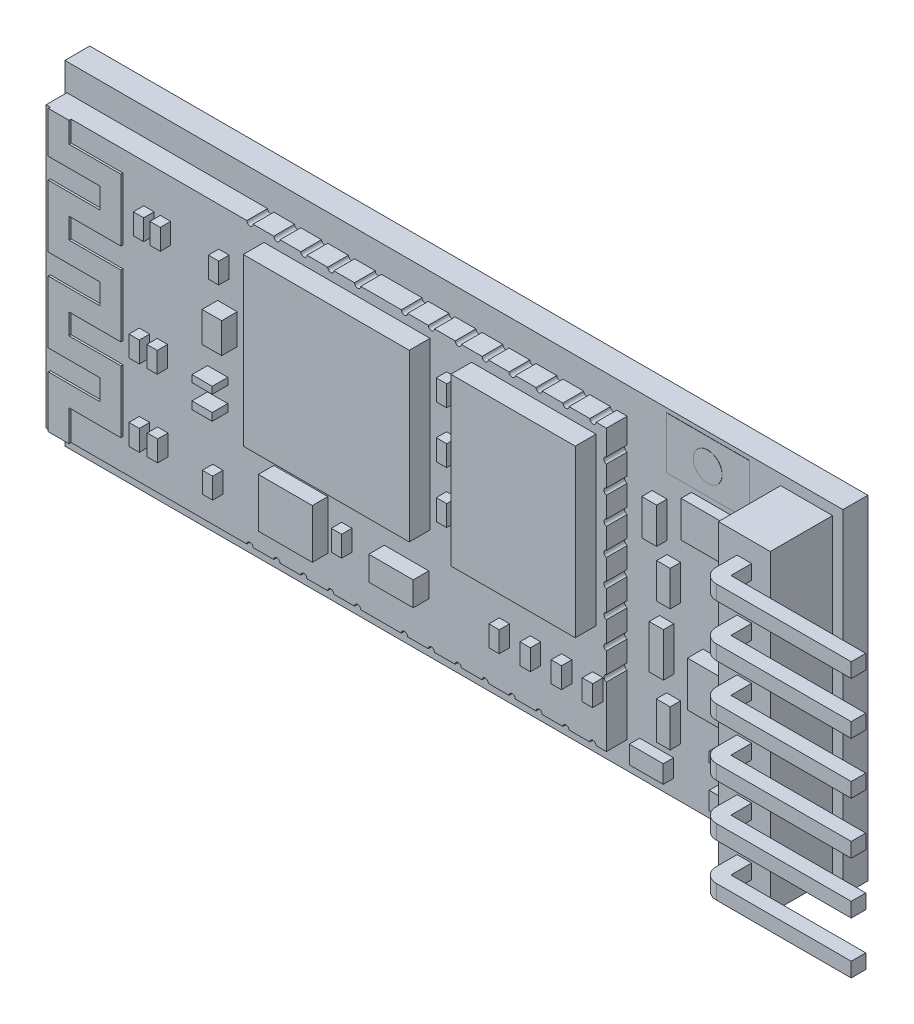
from build123d import *

# Parameters (mm, degrees)
IZIM2_W                       = 37.5
IZIM2_H                       = 16.1
Y_KSEKLIK_EKSTR_ZYON1_DEPTH   = 1.2
IZIM5_W                       = 2.5
IZIM5_H                       = 15.1
Y_KSEKLIK_EKSTR_ZYON2_DEPTH   = 3
IZIM6_W                       = 0.7
IZIM6_H                       = 0.7
Y_KSEKLIK_EKSTR_ZYON3_DEPTH   = 1
Y_KSEKLIK_EKSTR_ZYON3_2_DEPTH = 1
Y_KSEKLIK_EKSTR_ZYON3_3_DEPTH = 1
Y_KSEKLIK_EKSTR_ZYON3_4_DEPTH = 1
Y_KSEKLIK_EKSTR_ZYON3_5_DEPTH = 1
Y_KSEKLIK_EKSTR_ZYON3_6_DEPTH = 1
Y_KSEKLIK_EKSTR_ZYON4_DEPTH   = 0.7
Y_KSEKLIK_EKSTR_ZYON5_DEPTH   = 0.7
Y_KSEKLIK_EKSTR_ZYON6_DEPTH   = 0.7
Y_KSEKLIK_EKSTR_ZYON7_DEPTH   = 0.7
Y_KSEKLIK_EKSTR_ZYON8_DEPTH   = 0.7
Y_KSEKLIK_EKSTR_ZYON9_DEPTH   = 0.7
IZIM14_W                      = 27
IZIM14_H                      = 13.5
Y_KSEKLIK_EKSTR_ZYON10_DEPTH  = 1
Y_KSEKLIK_EKSTR_ZYON11_DEPTH  = 0.1
IZIM16_W                      = 4
IZIM16_H                      = 2.5
Y_KSEKLIK_EKSTR_ZYON12_DEPTH  = 0.01
IZIM17_R                      = 0.693604575
Y_KSEKLIK_EKSTR_ZYON13_DEPTH  = 0.01
IZIM18_W                      = 6
IZIM18_H                      = 8
IZIM18_W_2                    = 8
Y_KSEKLIK_EKSTR_ZYON14_DEPTH  = 1
IZIM19_W                      = 0.5
IZIM19_H                      = 1
Y_KSEKLIK_EKSTR_ZYON15_DEPTH  = 0.5
IZIM22_W                      = 0.5
IZIM22_H                      = 1
Y_KSEKLIK_EKSTR_ZYON17_DEPTH  = 0.5
IZIM23_W                      = 2.602430281
IZIM23_H                      = 2.367545487
IZIM23_W_2                    = 2.141321068
IZIM23_H_2                    = 1.16646021
IZIM23_W_3                    = 0.976073465
IZIM23_H_3                    = 0.365909355
IZIM23_H_4                    = 0.334632026
IZIM23_W_4                    = 0.943360629
IZIM23_H_5                    = 1.46024084
Y_KSEKLIK_EKSTR_ZYON18_DEPTH  = 0.75
IZIM24_W                      = 2.706810909
IZIM24_H                      = 1.742911909
IZIM24_W_2                    = 0.716474489
IZIM24_H_2                    = 1.726632447
IZIM24_W_3                    = 0.652791749
IZIM24_H_3                    = 1.693765047
IZIM24_W_4                    = 0.684633119
IZIM24_H_4                    = 2.106353334
IZIM24_W_5                    = 0.668712434
IZIM24_H_5                    = 1.80079444
IZIM24_W_6                    = 1.634021616
IZIM24_H_6                    = 0.862411809
IZIM24_W_7                    = 1.353405455
IZIM24_H_7                    = 0.499412084
IZIM24_W_8                    = 1.368285393
IZIM24_H_8                    = 0.823617913
IZIM24_H_9                    = 0.791721171
Y_KSEKLIK_EKSTR_ZYON19_DEPTH  = 0.5
IZIM25_W                      = 3.051168615
IZIM25_H                      = 2.165639046
Y_KSEKLIK_EKSTR_ZYON20_DEPTH  = 0.75
KES_EKSTR_ZYON1_DEPTH         = 1
KES_EKSTR_ZYON2_DEPTH         = 1


with BuildPart() as part:
    # Çizim2 → Yükseklik-Ekstrüzyon1 (new body)
    with BuildSketch(Plane.XY):
        with Locations((18.75, 8.05)):
            Rectangle(IZIM2_W, IZIM2_H)
    extrude(amount=Y_KSEKLIK_EKSTR_ZYON1_DEPTH)

    # Çizim5 → Yükseklik-Ekstrüzyon2 (add)
    with BuildSketch(Plane.XY.offset(1.2)):
        with Locations((35.75, 8.05)):
            Rectangle(IZIM5_W, IZIM5_H)
    extrude(amount=Y_KSEKLIK_EKSTR_ZYON2_DEPTH)

    # Çizim14 → Yükseklik-Ekstrüzyon10 (add)
    with BuildSketch(Plane.XY.offset(1.2)):
        with Locations((13.6, 8.05)):
            Rectangle(IZIM14_W, IZIM14_H)
    extrude(amount=Y_KSEKLIK_EKSTR_ZYON10_DEPTH)

    # Çizim15 → Yükseklik-Ekstrüzyon11 (add)
    with BuildSketch(Plane.XY.offset(2.2)):
        Polygon((0.3, 1.3), (0.3, 3.8), (2.8, 3.8), (2.8, 4.8), (0.3, 4.8), (0.3, 7.8), (2.8, 7.8), (2.8, 8.8), (0.3, 8.8), (0.3, 11.8), (2.8, 11.8), (2.8, 12.8), (0.3, 12.8), (0.3, 14.8), (1.3, 14.8), (1.3, 13.8), (3.8, 13.8), (3.8, 10.8), (1.3, 10.8), (1.3, 9.8), (3.8, 9.8), (3.8, 6.8), (1.3, 6.8), (1.3, 5.8), (3.8, 5.8), (3.8, 2.8), (1.3, 2.8), (1.3, 1.3), align=None)
    extrude(amount=Y_KSEKLIK_EKSTR_ZYON11_DEPTH)



with BuildPart() as body_2:
    # Çizim6 → Yükseklik-Ekstrüzyon3 (new body)
    with BuildSketch(Plane.XY.offset(4.2)):
        with Locations((35.75, 1.8)):
            Rectangle(IZIM6_W, IZIM6_H)
    extrude(amount=Y_KSEKLIK_EKSTR_ZYON3_DEPTH)

    # Çizim8 → Yükseklik-Ekstrüzyon4 (add)
    with BuildSketch(Plane.XZ.offset(-1.45)):
        with BuildLine():
            Line((36.1, 5.2), (42.6, 5.2))
            Line((42.6, 5.2), (42.6, 5.9))
            Line((42.6, 5.9), (36.1, 5.9))
            ThreePointArc((36.1, 5.9), (35.605025253, 5.694974747), (35.4, 5.2))
            Line((35.4, 5.2), (36.1, 5.2))
        make_face()
    extrude(amount=-Y_KSEKLIK_EKSTR_ZYON4_DEPTH)


with BuildPart() as body_3:
    # Çizim6 → Y_kseklik-Ekstr_zyon3 2 (new body)
    with BuildSketch(Plane.XY.offset(4.2)):
        with Locations((35.75, 4.3)):
            Rectangle(IZIM6_W, IZIM6_H)
    extrude(amount=Y_KSEKLIK_EKSTR_ZYON3_2_DEPTH)

    # Çizim9 → Yükseklik-Ekstrüzyon5 (add)
    with BuildSketch(Plane.XZ.offset(-3.95)):
        with BuildLine():
            Line((36.1, 5.2), (42.6, 5.2))
            Line((42.6, 5.2), (42.6, 5.9))
            Line((42.6, 5.9), (36.1, 5.9))
            ThreePointArc((36.1, 5.9), (35.605025253, 5.694974747), (35.4, 5.2))
            Line((35.4, 5.2), (36.1, 5.2))
        make_face()
    extrude(amount=-Y_KSEKLIK_EKSTR_ZYON5_DEPTH)


with BuildPart() as body_4:
    # Çizim6 → Y_kseklik-Ekstr_zyon3 3 (new body)
    with BuildSketch(Plane.XY.offset(4.2)):
        with Locations((35.75, 9.3)):
            Rectangle(IZIM6_W, IZIM6_H)
    extrude(amount=Y_KSEKLIK_EKSTR_ZYON3_3_DEPTH)

    # Çizim11 → Yükseklik-Ekstrüzyon7 (add)
    with BuildSketch(Plane.XZ.offset(-8.95)):
        with BuildLine():
            Line((36.1, 5.2), (42.6, 5.2))
            Line((42.6, 5.2), (42.6, 5.9))
            Line((42.6, 5.9), (36.1, 5.9))
            ThreePointArc((36.1, 5.9), (35.605025253, 5.694974747), (35.4, 5.2))
            Line((35.4, 5.2), (36.1, 5.2))
        make_face()
    extrude(amount=-Y_KSEKLIK_EKSTR_ZYON7_DEPTH)


with BuildPart() as body_5:
    # Çizim6 → Y_kseklik-Ekstr_zyon3 4 (new body)
    with BuildSketch(Plane.XY.offset(4.2)):
        with Locations((35.75, 11.8)):
            Rectangle(IZIM6_W, IZIM6_H)
    extrude(amount=Y_KSEKLIK_EKSTR_ZYON3_4_DEPTH)

    # Çizim12 → Yükseklik-Ekstrüzyon8 (add)
    with BuildSketch(Plane.XZ.offset(-11.45)):
        with BuildLine():
            Line((36.1, 5.2), (42.6, 5.2))
            Line((42.6, 5.2), (42.6, 5.9))
            Line((42.6, 5.9), (36.1, 5.9))
            ThreePointArc((36.1, 5.9), (35.605025253, 5.694974747), (35.4, 5.2))
            Line((35.4, 5.2), (36.1, 5.2))
        make_face()
    extrude(amount=-Y_KSEKLIK_EKSTR_ZYON8_DEPTH)


with BuildPart() as body_6:
    # Çizim6 → Y_kseklik-Ekstr_zyon3 5 (new body)
    with BuildSketch(Plane.XY.offset(4.2)):
        with Locations((35.75, 14.3)):
            Rectangle(IZIM6_W, IZIM6_H)
    extrude(amount=Y_KSEKLIK_EKSTR_ZYON3_5_DEPTH)

    # Çizim13 → Yükseklik-Ekstrüzyon9 (add)
    with BuildSketch(Plane.XZ.offset(-13.95)):
        with BuildLine():
            Line((36.1, 5.2), (42.6, 5.2))
            Line((42.6, 5.2), (42.6, 5.9))
            Line((42.6, 5.9), (36.1, 5.9))
            ThreePointArc((36.1, 5.9), (35.605025253, 5.694974747), (35.4, 5.2))
            Line((35.4, 5.2), (36.1, 5.2))
        make_face()
    extrude(amount=-Y_KSEKLIK_EKSTR_ZYON9_DEPTH)


with BuildPart() as body_7:
    # Çizim6 → Y_kseklik-Ekstr_zyon3 6 (new body)
    with BuildSketch(Plane.XY.offset(4.2)):
        with Locations((35.75, 6.8)):
            Rectangle(IZIM6_W, IZIM6_H)
    extrude(amount=Y_KSEKLIK_EKSTR_ZYON3_6_DEPTH)

    # Çizim10 → Yükseklik-Ekstrüzyon6 (add)
    with BuildSketch(Plane.XZ.offset(-6.45)):
        with BuildLine():
            Line((36.1, 5.2), (42.6, 5.2))
            Line((42.6, 5.2), (42.6, 5.9))
            Line((42.6, 5.9), (36.1, 5.9))
            ThreePointArc((36.1, 5.9), (35.605025253, 5.694974747), (35.4, 5.2))
            Line((35.4, 5.2), (36.1, 5.2))
        make_face()
    extrude(amount=-Y_KSEKLIK_EKSTR_ZYON6_DEPTH)


with BuildPart() as body_8:
    # Çizim16 → Yükseklik-Ekstrüzyon12 (new body)
    with BuildSketch(Plane.XY.offset(1.2)):
        with Locations((31, 14.65)):
            Rectangle(IZIM16_W, IZIM16_H)
    extrude(amount=Y_KSEKLIK_EKSTR_ZYON12_DEPTH)


with BuildPart() as part_1:
    add(part.part)

    add(body_8.part)  # Yükseklik-Ekstrüzyon13 merges body 8
    # Çizim17 → Yükseklik-Ekstrüzyon13 (add)
    with BuildSketch(Plane.XY.offset(1.21)):
        with Locations(Location((31, 14.65, 0), (0, 0, 180))):
            Circle(IZIM17_R)
    extrude(amount=Y_KSEKLIK_EKSTR_ZYON13_DEPTH)

    # Çizim18 → Yükseklik-Ekstrüzyon14 (add)
    with BuildSketch(Plane.XY.offset(2.2)):
        with Locations((23.600429337, 10.3)):
            Rectangle(IZIM18_W, IZIM18_H)
        with Locations((14.600429337, 10.3)):
            Rectangle(IZIM18_W_2, IZIM18_H)
    extrude(amount=Y_KSEKLIK_EKSTR_ZYON14_DEPTH)

    # Çizim19 → Yükseklik-Ekstrüzyon15 (add)
    with BuildSketch(Plane.XY.offset(2.2)):
        with Locations((5.05, 12.430030241)):
            Rectangle(IZIM19_W, IZIM19_H)
        with Locations((5.85, 12.430030241)):
            Rectangle(IZIM19_W, IZIM19_H)
        with Locations((8.665669621, 12.430030241)):
            Rectangle(IZIM19_W, IZIM19_H)
    extrude(amount=Y_KSEKLIK_EKSTR_ZYON15_DEPTH)

    # Çizim22 → Yükseklik-Ekstrüzyon17 (add)
    with BuildSketch(Plane.XY.offset(2.2)):
        with Locations((4.838962256, 7.221997086)):
            Rectangle(IZIM22_W, IZIM22_H)
        with Locations((5.701638758, 7.221997086)):
            Rectangle(IZIM22_W, IZIM22_H)
        with Locations((4.838818901, 3.533540421)):
            Rectangle(IZIM22_W, IZIM22_H)
        with Locations((5.720100061, 3.533540421)):
            Rectangle(IZIM22_W, IZIM22_H)
        with Locations((8.374321984, 3.306212795)):
            Rectangle(IZIM22_W, IZIM22_H)
        with Locations((19.650429337, 12.8)):
            Rectangle(IZIM22_W, IZIM22_H)
        with Locations((19.650429337, 10.3)):
            Rectangle(IZIM22_W, IZIM22_H)
        with Locations((19.650429337, 7.8)):
            Rectangle(IZIM22_W, IZIM22_H)
        with Locations((26.685091813, 3.8)):
            Rectangle(IZIM22_W, IZIM22_H)
        with Locations((25.185091813, 3.8)):
            Rectangle(IZIM22_W, IZIM22_H)
        with Locations((23.685091813, 3.8)):
            Rectangle(IZIM22_W, IZIM22_H)
        with Locations((22.185091813, 3.8)):
            Rectangle(IZIM22_W, IZIM22_H)
        with Locations((14.590448244, 3.990810695)):
            Rectangle(IZIM22_W, IZIM22_H)
    extrude(amount=Y_KSEKLIK_EKSTR_ZYON17_DEPTH)

    # Çizim23 → Yükseklik-Ekstrüzyon18 (add)
    with BuildSketch(Plane.XY.offset(2.2)):
        with Locations((12.376318164, 4.047967675)):
            Rectangle(IZIM23_W, IZIM23_H)
        with Locations((17.469520012, 3.979476737)):
            Rectangle(IZIM23_W_2, IZIM23_H_2)
        with Locations((8.364147087, 6.520171395)):
            Rectangle(IZIM23_W_3, IZIM23_H_3)
        with Locations((8.364147087, 7.631045899)):
            Rectangle(IZIM23_W_3, IZIM23_H_4)
        with Locations((8.835827401, 10.033036523)):
            Rectangle(IZIM23_W_4, IZIM23_H_5)
    extrude(amount=Y_KSEKLIK_EKSTR_ZYON18_DEPTH)

    # Çizim24 → Yükseklik-Ekstrüzyon19 (add)
    with BuildSketch(Plane.XY.offset(1.2)):
        with Locations((31.553494099, 12.29905928)):
            Rectangle(IZIM24_W, IZIM24_H)
        with Locations((28.662605916, 11.435743057)):
            Rectangle(IZIM24_W_2, IZIM24_H_2)
        with Locations((29.347239034, 9.137191125)):
            Rectangle(IZIM24_W_3, IZIM24_H_3)
        with Locations((29.004922476, 6.207999371)):
            Rectangle(IZIM24_W_4, IZIM24_H_4)
        with Locations((29.339278692, 3.303381049)):
            Rectangle(IZIM24_W_5, IZIM24_H_5)
        with Locations((28.522267884, 1.231924795)):
            Rectangle(IZIM24_W_6, IZIM24_H_6)
        with Locations((32.230196826, 1.231924795)):
            Rectangle(IZIM24_W_7, IZIM24_H_6)
        with Locations((32.230196826, 3.053675007)):
            Rectangle(IZIM24_W_7, IZIM24_H_7)
        with Locations((32.704361967, 10.395882605)):
            Rectangle(IZIM24_W_8, IZIM24_H_8)
        with Locations((32.704361967, 8.686169187)):
            Rectangle(IZIM24_W_8, IZIM24_H_9)
    extrude(amount=Y_KSEKLIK_EKSTR_ZYON19_DEPTH)

    # Çizim25 → Yükseklik-Ekstrüzyon20 (add)
    with BuildSketch(Plane.XY.offset(1.2)):
        with Locations((32.282514113, 5.823350592)):
            Rectangle(IZIM25_W, IZIM25_H)
    extrude(amount=Y_KSEKLIK_EKSTR_ZYON20_DEPTH)

    # Çizim27 → Kes-Ekstrüzyon1 (cut)
    with BuildSketch(Plane.XY.offset(2.2)):
        with BuildLine():
            Line((26.6, 14.8), (26.3, 14.8))
            ThreePointArc((26.3, 14.8), (26.45, 14.65), (26.6, 14.8))
        make_face()
        with BuildLine():
            Line((25.3, 14.8), (25.004468137, 14.8))
            ThreePointArc((25.004468137, 14.8), (25.152234068, 14.652234068), (25.3, 14.8))
        make_face()
        with BuildLine():
            Line((23.708936273, 14.8), (24.004468137, 14.8))
            ThreePointArc((24.004468137, 14.8), (23.856702205, 14.652234068), (23.708936273, 14.8))
        make_face()
        with BuildLine():
            Line((22.408936273, 14.8), (22.708936273, 14.8))
            ThreePointArc((22.708936273, 14.8), (22.558936273, 14.65), (22.408936273, 14.8))
        make_face()
        with BuildLine():
            Line((21.408936273, 14.8), (21.108936273, 14.8))
            ThreePointArc((21.108936273, 14.8), (21.258936273, 14.65), (21.408936273, 14.8))
        make_face()
        with BuildLine():
            Line((20.108936273, 14.8), (19.81340441, 14.8))
            ThreePointArc((19.81340441, 14.8), (19.961170341, 14.652234068), (20.108936273, 14.8))
        make_face()
        with BuildLine():
            Line((18.517872546, 14.8), (18.81340441, 14.8))
            ThreePointArc((18.81340441, 14.8), (18.665638478, 14.652234068), (18.517872546, 14.8))
        make_face()
        with BuildLine():
            Line((17.217872546, 14.8), (17.517872546, 14.8))
            ThreePointArc((17.517872546, 14.8), (17.367872546, 14.65), (17.217872546, 14.8))
        make_face()
        with BuildLine():
            Line((15.261871651, 14.8), (14.961871651, 14.8))
            ThreePointArc((14.961871651, 14.8), (15.111871651, 14.65), (15.261871651, 14.8))
        make_face()
        with BuildLine():
            Line((13.961871651, 14.8), (13.666339787, 14.8))
            ThreePointArc((13.666339787, 14.8), (13.814105719, 14.652234068), (13.961871651, 14.8))
        make_face()
        with BuildLine():
            Line((12.370807924, 14.8), (12.666339787, 14.8))
            ThreePointArc((12.666339787, 14.8), (12.518573856, 14.652234068), (12.370807924, 14.8))
        make_face()
        with BuildLine():
            Line((11.070807924, 14.8), (11.370807924, 14.8))
            ThreePointArc((11.370807924, 14.8), (11.220807924, 14.65), (11.070807924, 14.8))
        make_face()
        with BuildLine():
            Line((10.070807924, 14.8), (9.770807924, 14.8))
            ThreePointArc((9.770807924, 14.8), (9.920807924, 14.65), (10.070807924, 14.8))
        make_face()
        with BuildLine():
            Line((10.070807924, 1.3), (9.770807924, 1.3))
            ThreePointArc((9.770807924, 1.3), (9.920807924, 1.45), (10.070807924, 1.3))
        make_face()
        with BuildLine():
            Line((11.070807924, 1.3), (11.370807924, 1.3))
            ThreePointArc((11.370807924, 1.3), (11.220807924, 1.45), (11.070807924, 1.3))
        make_face()
        with BuildLine():
            Line((12.370807924, 1.3), (12.666339787, 1.3))
            ThreePointArc((12.666339787, 1.3), (12.518573856, 1.447765932), (12.370807924, 1.3))
        make_face()
        with BuildLine():
            Line((13.961871651, 1.3), (13.666339787, 1.3))
            ThreePointArc((13.666339787, 1.3), (13.814105719, 1.447765932), (13.961871651, 1.3))
        make_face()
        with BuildLine():
            Line((15.261871651, 1.3), (14.961871651, 1.3))
            ThreePointArc((14.961871651, 1.3), (15.111871651, 1.45), (15.261871651, 1.3))
        make_face()
        with BuildLine():
            Line((17.217872546, 1.3), (17.517872546, 1.3))
            ThreePointArc((17.517872546, 1.3), (17.367872546, 1.45), (17.217872546, 1.3))
        make_face()
        with BuildLine():
            Line((18.517872546, 1.3), (18.81340441, 1.3))
            ThreePointArc((18.81340441, 1.3), (18.665638478, 1.447765932), (18.517872546, 1.3))
        make_face()
        with BuildLine():
            Line((20.108936273, 1.3), (19.81340441, 1.3))
            ThreePointArc((19.81340441, 1.3), (19.961170341, 1.447765932), (20.108936273, 1.3))
        make_face()
        with BuildLine():
            Line((21.408936273, 1.3), (21.108936273, 1.3))
            ThreePointArc((21.108936273, 1.3), (21.258936273, 1.45), (21.408936273, 1.3))
        make_face()
        with BuildLine():
            Line((22.408936273, 1.3), (22.708936273, 1.3))
            ThreePointArc((22.708936273, 1.3), (22.558936273, 1.45), (22.408936273, 1.3))
        make_face()
        with BuildLine():
            Line((23.708936273, 1.3), (24.004468137, 1.3))
            ThreePointArc((24.004468137, 1.3), (23.856702205, 1.447765932), (23.708936273, 1.3))
        make_face()
        with BuildLine():
            Line((25.3, 1.3), (25.004468137, 1.3))
            ThreePointArc((25.004468137, 1.3), (25.152234068, 1.447765932), (25.3, 1.3))
        make_face()
        with BuildLine():
            Line((26.6, 1.3), (26.3, 1.3))
            ThreePointArc((26.3, 1.3), (26.45, 1.45), (26.6, 1.3))
        make_face()
    extrude(amount=-KES_EKSTR_ZYON1_DEPTH, mode=Mode.SUBTRACT)

    # Çizim28 → Kes-Ekstrüzyon2 (cut)
    with BuildSketch(Plane.XY.offset(2.2)):
        with BuildLine():
            Line((27.1, 13.300479938), (27.1, 13.599833571))
            ThreePointArc((27.1, 13.599833571), (26.978735777, 13.450156754), (27.1, 13.300479938))
        make_face()
        with BuildLine():
            Line((27.1, 12.300479938), (27.1, 12.001126305))
            ThreePointArc((27.1, 12.001126305), (26.978735777, 12.150803122), (27.1, 12.300479938))
        make_face()
        with BuildLine():
            Line((27.1, 10.701772672), (27.1, 11.001126305))
            ThreePointArc((27.1, 11.001126305), (26.978735777, 10.851449489), (27.1, 10.701772672))
        make_face()
        with BuildLine():
            Line((27.1, 9.701772672), (27.1, 9.40241904))
            ThreePointArc((27.1, 9.40241904), (26.978735777, 9.552095856), (27.1, 9.701772672))
        make_face()
        with BuildLine():
            Line((27.1, 8.103065407), (27.1, 8.40241904))
            ThreePointArc((27.1, 8.40241904), (26.978735777, 8.252742223), (27.1, 8.103065407))
        make_face()
        with BuildLine():
            Line((27.1, 7.103065407), (27.1, 6.803711774))
            ThreePointArc((27.1, 6.803711774), (26.978735777, 6.953388591), (27.1, 7.103065407))
        make_face()
        with BuildLine():
            Line((27.1, 5.504358141), (27.1, 5.803711774))
            ThreePointArc((27.1, 5.803711774), (26.978735777, 5.654034958), (27.1, 5.504358141))
        make_face()
        with BuildLine():
            Line((27.1, 4.504358141), (27.1, 4.205004509))
            ThreePointArc((27.1, 4.205004509), (26.978735777, 4.354681325), (27.1, 4.504358141))
        make_face()
    extrude(amount=-KES_EKSTR_ZYON2_DEPTH, mode=Mode.SUBTRACT)


solid = Compound([body_2.part, body_3.part, body_4.part, body_5.part, body_6.part, body_7.part, part_1.part])
